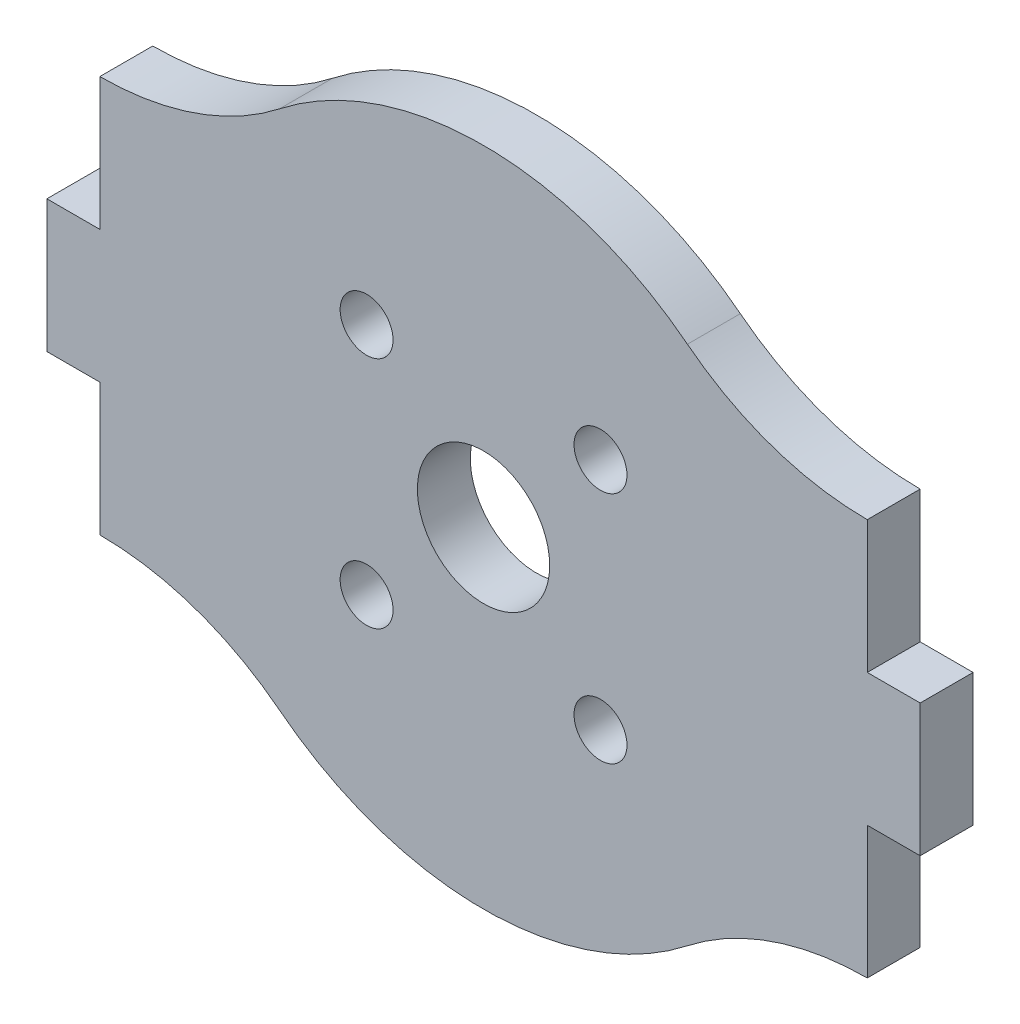
from build123d import *

# Parameters (mm, degrees)
ESQUISSE1_R        = 5
ESQUISSE1_R_2      = 2
BOSS_EXTRU_1_DEPTH = 4


with BuildPart() as part:
    # Esquisse1 → Boss.-Extru.1 (new body)
    with BuildSketch(Plane.XY):
        with BuildLine():
            Line((33, -5), (33, 5))
            Line((33, 5), (29, 5))
            Line((29, 5), (29, 15))
            ThreePointArc((29, 15), (21.811905433, 16.204525755), (15.409139214, 19.686503719))
            ThreePointArc((15.409139214, 19.686503719), (0, 25), (-15.409139214, 19.686503719))
            ThreePointArc((-15.409139214, 19.686503719), (-21.811905433, 16.204525755), (-29, 15))
            Line((-29, 15), (-29, 5))
            Line((-29, 5), (-33, 5))
            Line((-33, 5), (-33, -5))
            Line((-33, -5), (-29, -5))
            Line((-29, -5), (-29, -15))
            ThreePointArc((-29, -15), (-21.811905433, -16.204525755), (-15.409139214, -19.686503719))
            ThreePointArc((-15.409139214, -19.686503719), (0, -25), (15.409139214, -19.686503719))
            ThreePointArc((15.409139214, -19.686503719), (21.811905433, -16.204525755), (29, -15))
            Line((29, -15), (29, -5))
            Line((29, -5), (33, -5))
        make_face()
        Circle(ESQUISSE1_R, mode=Mode.SUBTRACT)
        with Locations((-8.838834765, 8.838834765)):
            Circle(ESQUISSE1_R_2, mode=Mode.SUBTRACT)
        with Locations((8.838834765, 8.838834765)):
            Circle(ESQUISSE1_R_2, mode=Mode.SUBTRACT)
        with Locations((8.838834765, -8.838834765)):
            Circle(ESQUISSE1_R_2, mode=Mode.SUBTRACT)
        with Locations((-8.838834765, -8.838834765)):
            Circle(ESQUISSE1_R_2, mode=Mode.SUBTRACT)
    extrude(amount=BOSS_EXTRU_1_DEPTH)


solid = part.part
